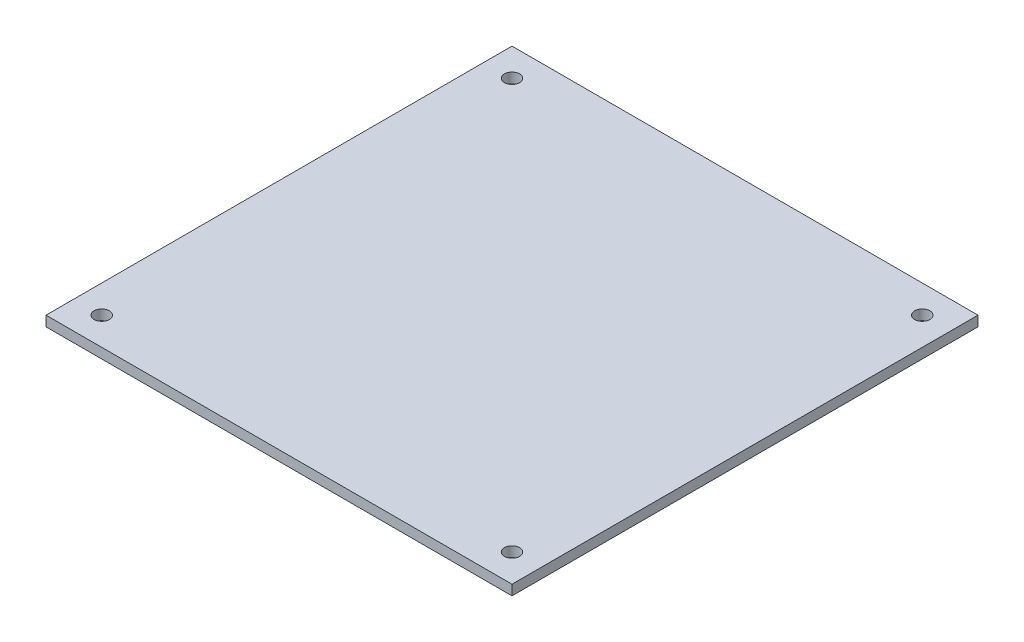
from build123d import *

# Parameters (mm, degrees)
SKETCH1_R           = 1.5
BOSS_EXTRUDE1_DEPTH = 2


with BuildPart() as part:
    # Sketch1 → Boss-Extrude1 (new body)
    with BuildSketch(Plane(origin=(0, 0, 0), x_dir=(1, 0, 0), z_dir=(0, 1, 0))):
        Polygon((46.087228268, 37.194976507), (46.087228268, 46.194976507), (-36.912771732, 46.194976507), (-45.912771732, 46.194976507), (-45.912771732, -36.805023493), (-45.912771732, -45.805023493), (37.087228268, -45.805023493), (46.087228268, -45.805023493), align=None)
        with Locations((-40.412771732, -40.305023493)):
            Circle(SKETCH1_R, mode=Mode.SUBTRACT)
        with Locations((40.587228268, -40.305023493)):
            Circle(SKETCH1_R, mode=Mode.SUBTRACT)
        with Locations((-40.412771732, 40.694976507)):
            Circle(SKETCH1_R, mode=Mode.SUBTRACT)
        with Locations((40.587228268, 40.694976507)):
            Circle(SKETCH1_R, mode=Mode.SUBTRACT)
    extrude(amount=BOSS_EXTRUDE1_DEPTH)


solid = part.part
